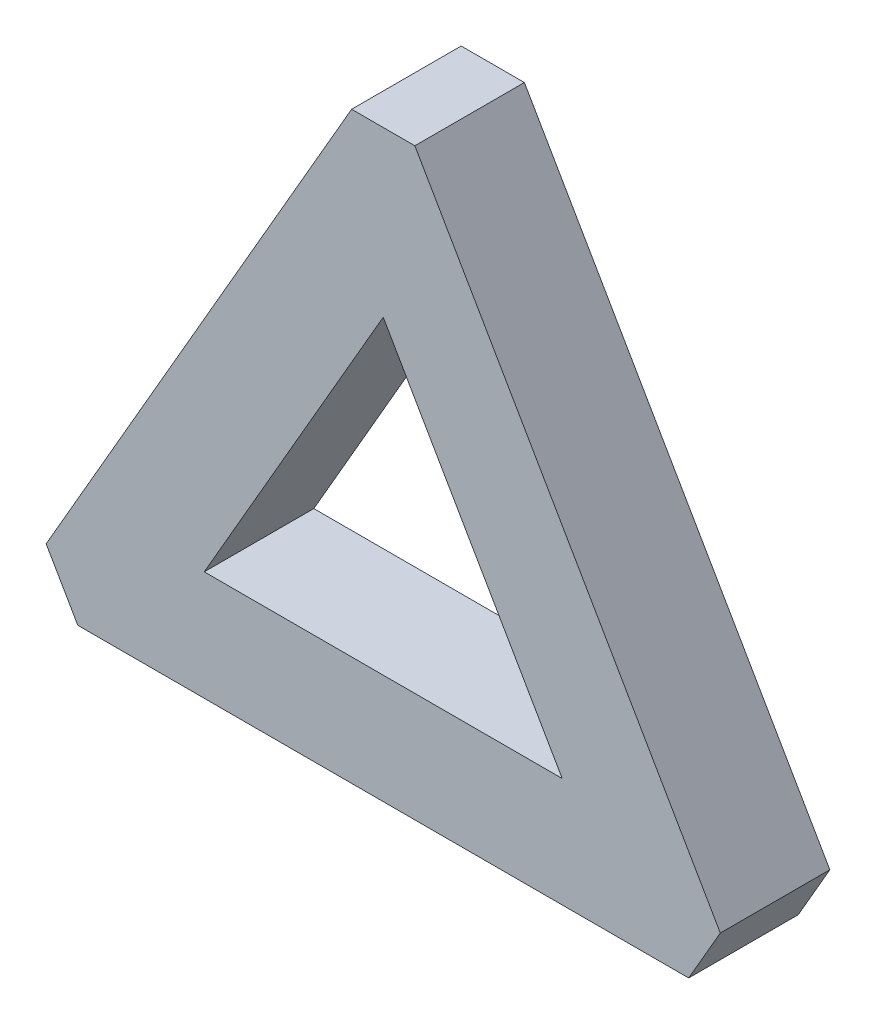
from build123d import *

# Parameters (mm, degrees)
EXTRUDE_4_DEPTH = 20


with BuildPart() as part:
    # 草图7 → 凸台-拉伸4 (new body)
    with BuildSketch(Plane.XY):
        Polygon((-33.910919067, 18.999592163), (-61.547005384, -28.867513459), (-55.773502692, -38.867513459), (1.462534319, -38.867513459), (55.773502692, -38.867513459), (61.547005384, -28.867513459), (37.633660722, 12.551614473), (5.773502692, 67.735026919), (-5.773502692, 67.735026919), align=None)
        Polygon((-16.951439693, 8.374272109), (0, 37.735026919), (18.097391255, 6.389425782), (32.679491924, -18.867513459), (0.821995205, -18.867513459), (-32.679491924, -18.867513459), align=None, mode=Mode.SUBTRACT)
    extrude(amount=EXTRUDE_4_DEPTH)


solid = part.part
